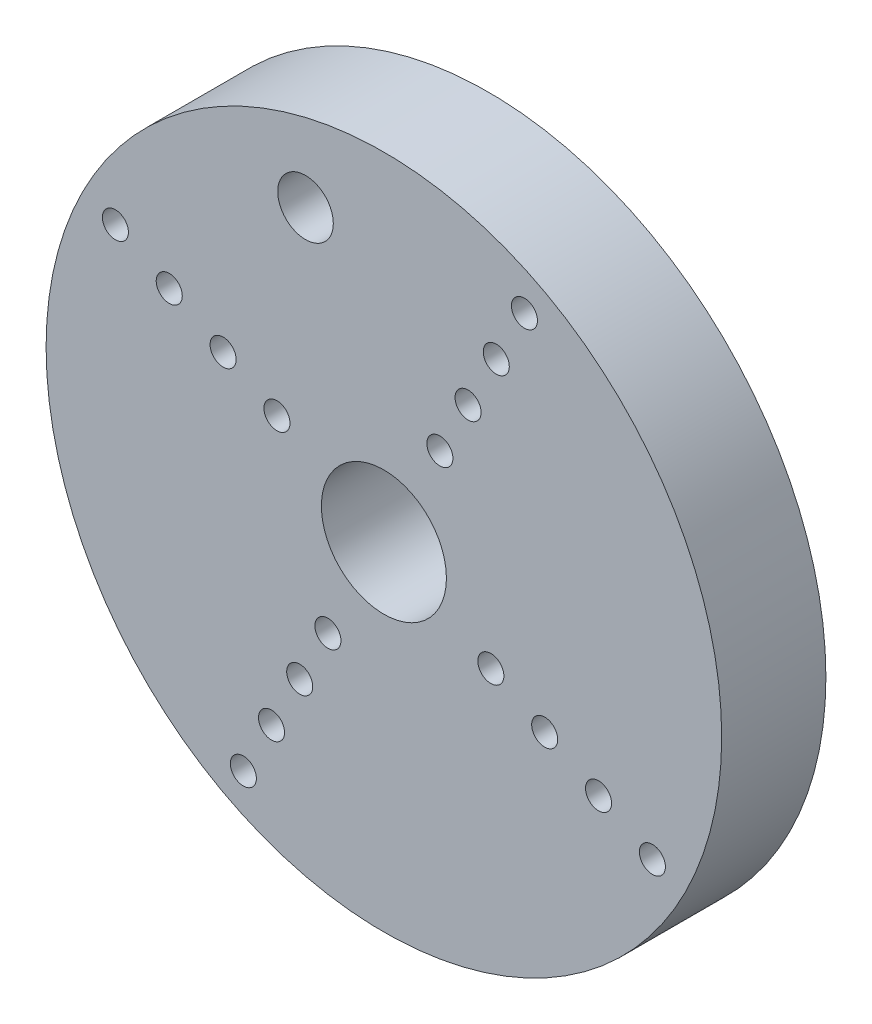
from build123d import *

# Parameters (mm, degrees)
SKETCH1_R           = 19.45
SKETCH1_R_2         = 0.75
SKETCH1_R_3         = 3.6
SKETCH1_R_4         = 1.599999975
BOSS_EXTRUDE1_DEPTH = 6


with BuildPart() as part:
    # Sketch1 → Boss-Extrude1 (new body)
    with BuildSketch(Plane.XY):
        with Locations((216.229766611, 107.1388)):
            Circle(SKETCH1_R)
        with Locations((224.322698445, 122.598649751)):
            Circle(SKETCH1_R_2, mode=Mode.SUBTRACT)
        with Locations((222.699474295, 119.497820288)):
            Circle(SKETCH1_R_2, mode=Mode.SUBTRACT)
        with Locations((221.076250145, 116.396990825)):
            Circle(SKETCH1_R_2, mode=Mode.SUBTRACT)
        with Locations((219.453025995, 113.296161362)):
            Circle(SKETCH1_R_2, mode=Mode.SUBTRACT)
        with Locations((231.689616361, 99.045868165)):
            Circle(SKETCH1_R_2, mode=Mode.SUBTRACT)
        with Locations((228.588786898, 100.669092315)):
            Circle(SKETCH1_R_2, mode=Mode.SUBTRACT)
        with Locations((225.487957435, 102.292316466)):
            Circle(SKETCH1_R_2, mode=Mode.SUBTRACT)
        with Locations((222.387127973, 103.915540616)):
            Circle(SKETCH1_R_2, mode=Mode.SUBTRACT)
        with Locations((208.136834776, 91.678950249)):
            Circle(SKETCH1_R_2, mode=Mode.SUBTRACT)
        with Locations((209.760058926, 94.779779712)):
            Circle(SKETCH1_R_2, mode=Mode.SUBTRACT)
        with Locations((211.383283076, 97.880609175)):
            Circle(SKETCH1_R_2, mode=Mode.SUBTRACT)
        with Locations((213.006507226, 100.981438638)):
            Circle(SKETCH1_R_2, mode=Mode.SUBTRACT)
        with Locations((200.76991686, 115.231731835)):
            Circle(SKETCH1_R_2, mode=Mode.SUBTRACT)
        with Locations((203.870746323, 113.608507685)):
            Circle(SKETCH1_R_2, mode=Mode.SUBTRACT)
        with Locations((206.971575786, 111.985283534)):
            Circle(SKETCH1_R_2, mode=Mode.SUBTRACT)
        with Locations((210.072405248, 110.362059384)):
            Circle(SKETCH1_R_2, mode=Mode.SUBTRACT)
        with Locations((216.229766611, 107.1388)):
            Circle(SKETCH1_R_3, mode=Mode.SUBTRACT)
        with Locations((211.717350559, 121.565450451)):
            Circle(SKETCH1_R_4, mode=Mode.SUBTRACT)
    extrude(amount=BOSS_EXTRUDE1_DEPTH)


solid = part.part
